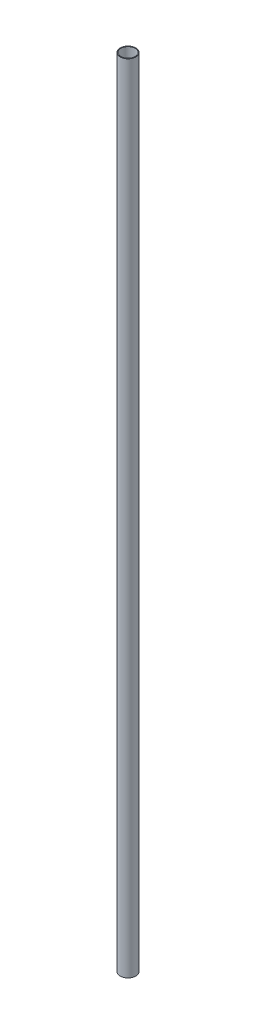
from build123d import *

# Parameters (mm, degrees)
SKETCH1_R           = 10.541
SKETCH1_R_2         = 9.525
BOSS_EXTRUDE1_DEPTH = 1066.8


with BuildPart() as part:
    # Sketch1 → Boss-Extrude1 (new body)
    with BuildSketch(Plane(origin=(0, 0, 0), x_dir=(1, 0, 0), z_dir=(0, 1, 0))):
        Circle(SKETCH1_R)
        Circle(SKETCH1_R_2, mode=Mode.SUBTRACT)
    extrude(amount=BOSS_EXTRUDE1_DEPTH)


solid = part.part
